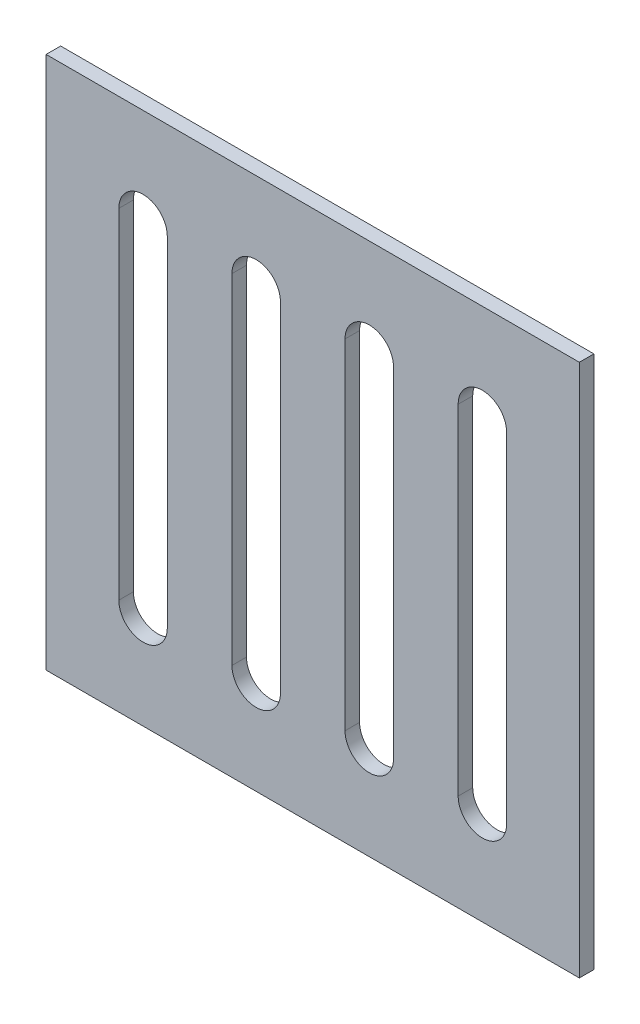
from build123d import *

# Parameters (mm, degrees)
IZIM1_W                     = 110
IZIM1_H                     = 110
Y_KSEKLIK_EKSTR_ZYON1_DEPTH = 3
KES_EKSTR_ZYON1_DEPTH       = 10


with BuildPart() as part:
    # Çizim1 → Yükseklik-Ekstrüzyon1 (new body)
    with BuildSketch(Plane.XY):
        with Locations((55, -55)):
            Rectangle(IZIM1_W, IZIM1_H)
    extrude(amount=Y_KSEKLIK_EKSTR_ZYON1_DEPTH)

    # Çizim2 → Kes-Ekstrüzyon1 (cut)
    with BuildSketch(Plane.XY.offset(3)):
        with BuildLine():
            Line((25, -20), (25, -90))
            ThreePointArc((25, -90), (20, -95), (15, -90))
            Line((15, -90), (15, -20))
            ThreePointArc((15, -20), (20, -15), (25, -20))
        make_face()
        with BuildLine():
            Line((38.333333333, -20), (38.333333333, -90))
            ThreePointArc((38.333333333, -90), (43.333333333, -95), (48.333333333, -90))
            Line((48.333333333, -90), (48.333333333, -20))
            ThreePointArc((48.333333333, -20), (43.333333333, -15), (38.333333333, -20))
        make_face()
        with BuildLine():
            Line((61.666666667, -20), (61.666666667, -90))
            ThreePointArc((61.666666667, -90), (66.666666667, -95), (71.666666667, -90))
            Line((71.666666667, -90), (71.666666667, -20))
            ThreePointArc((71.666666667, -20), (66.666666667, -15), (61.666666667, -20))
        make_face()
        with BuildLine():
            Line((85, -20), (85, -90))
            ThreePointArc((85, -90), (90, -95), (95, -90))
            Line((95, -90), (95, -20))
            ThreePointArc((95, -20), (90, -15), (85, -20))
        make_face()
    extrude(amount=-KES_EKSTR_ZYON1_DEPTH, mode=Mode.SUBTRACT)


solid = part.part
